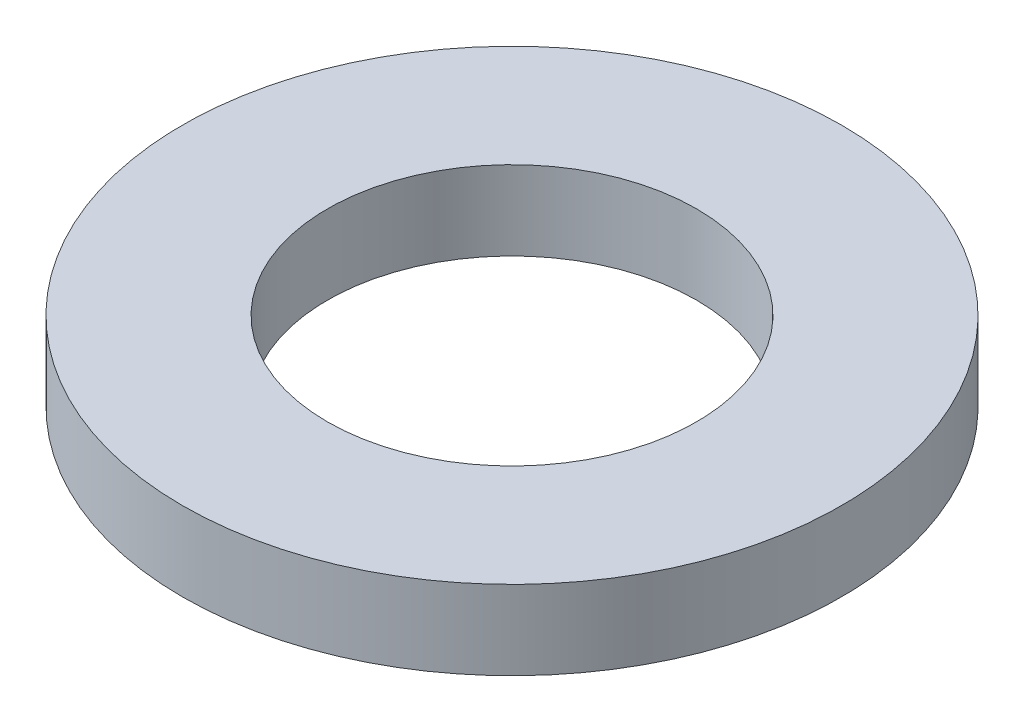
from build123d import *

# Parameters (mm, degrees)
SKIZZE1_R                       = 7.5
SKIZZE1_R_2                     = 4.2
AUFSATZ_LINEAR_AUSTRAGEN1_DEPTH = 1.8


with BuildPart() as part:
    # Skizze1 → Aufsatz-Linear austragen1 (new body)
    with BuildSketch(Plane(origin=(0, 0, 0), x_dir=(1, 0, 0), z_dir=(0, 1, 0))):
        Circle(SKIZZE1_R)
        Circle(SKIZZE1_R_2, mode=Mode.SUBTRACT)
    extrude(amount=AUFSATZ_LINEAR_AUSTRAGEN1_DEPTH)


solid = part.part
